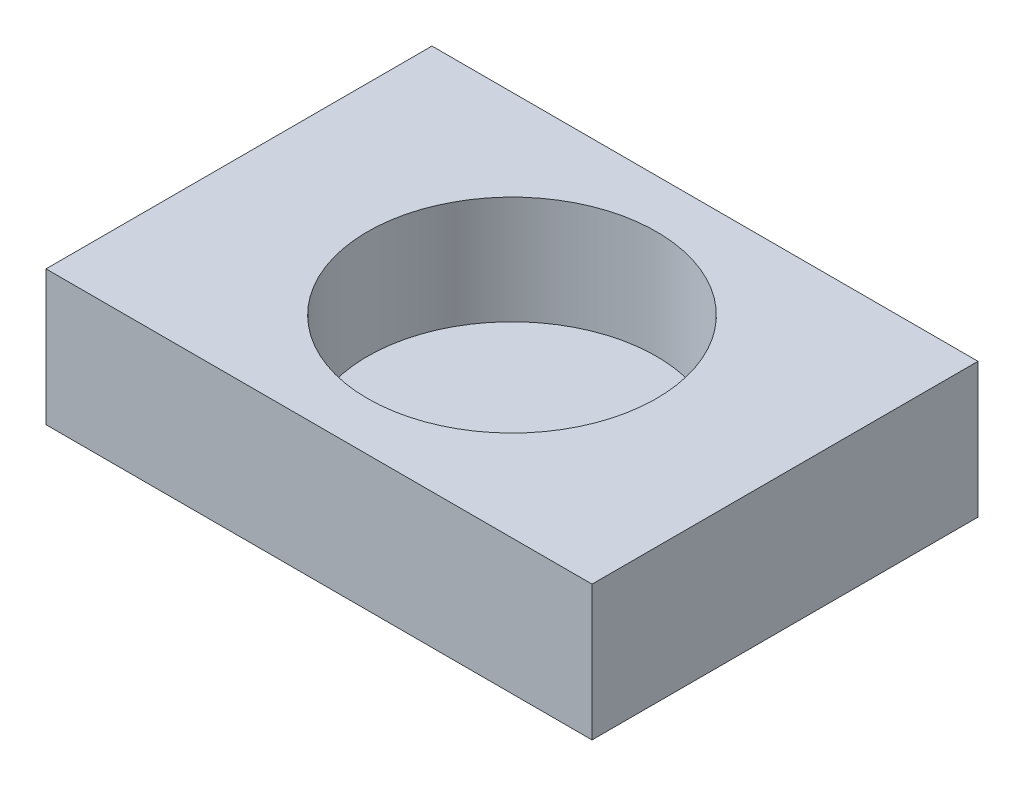
from build123d import *

# Parameters (mm, degrees)
SKETCH2_W           = 202.291057074
SKETCH2_H           = 142.989
BOSS_EXTRUDE2_DEPTH = 50
SKETCH3_R           = 53.540101
CUT_EXTRUDE2_DEPTH  = 40


with BuildPart() as part:
    # Sketch2 → Boss-Extrude2 (new body)
    with BuildSketch(Plane(origin=(0, 0, 0), x_dir=(1, 0, 0), z_dir=(0, 1, 0))):
        Rectangle(SKETCH2_W, SKETCH2_H)
    extrude(amount=BOSS_EXTRUDE2_DEPTH)

    # Sketch3 → Cut-Extrude2 (cut)
    with BuildSketch(Plane(origin=(0, 50, -33.697674061), x_dir=(1, 0, 0), z_dir=(0, 1, 0))):
        with Locations((0, -33.697674061)):
            Circle(SKETCH3_R)
    extrude(amount=-CUT_EXTRUDE2_DEPTH, mode=Mode.SUBTRACT)


solid = part.part
